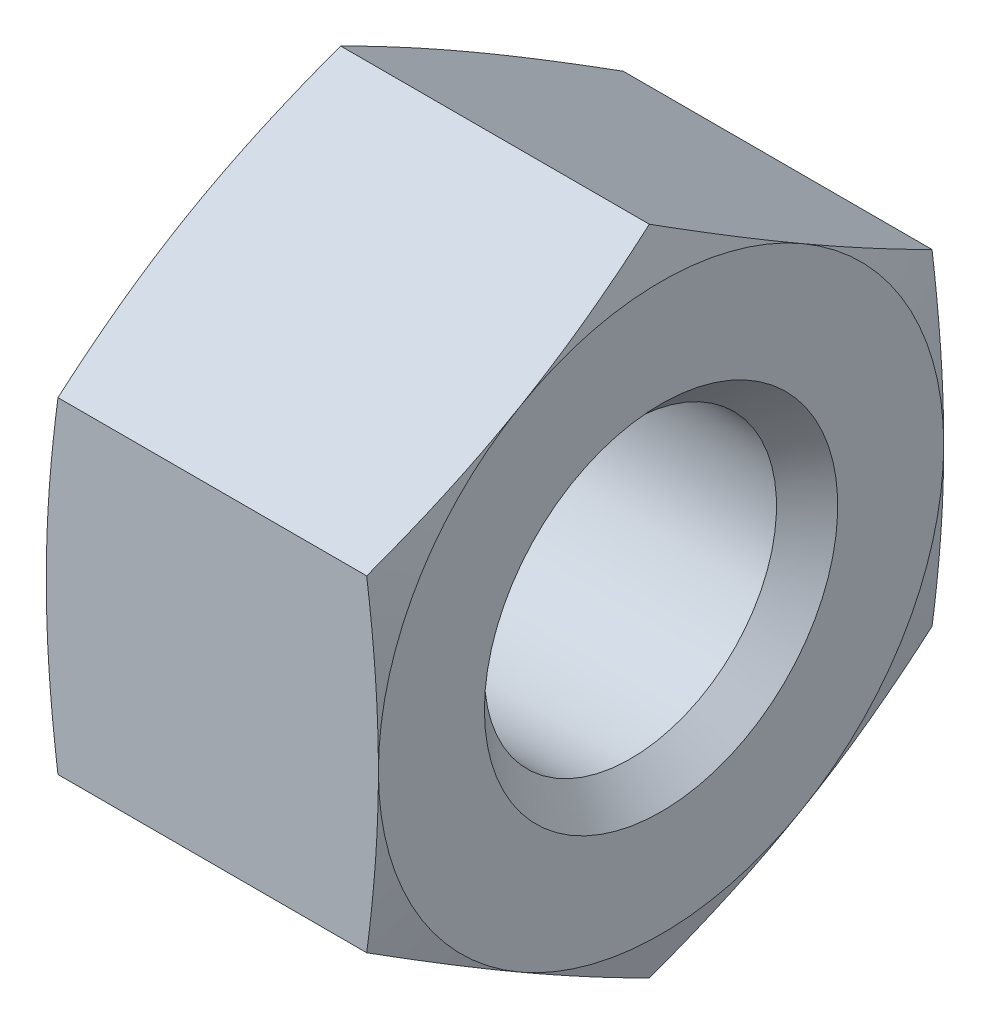
from build123d import *

# Parameters (mm, degrees)
SKETCH3_W               = 16
SKETCH3_H               = 16
CUT_EXTRUDE1_DEPTH      = 4.7
CUT_EXTRUDE1_DEPTH_BACK = 4.7


with BuildPart() as part:
    # Sketch1 → Revolve1 (revolve)
    with BuildSketch(Plane.XY):
        Polygon((-2.35, 0), (-2.35, 4), (-2.135640646, 4.8), (2.135640646, 4.8), (2.35, 4), (2.35, 0), align=None)
    revolve(axis=Axis((2.35, 0, 0), (-1, 0, 0)))

    # Sketch2 → Cut-Revolve1 (revolve, cut)
    with BuildSketch(Plane.XY):
        Polygon((-2.35, 0), (-2.35, 2.5), (-1.917, 2.067), (1.917, 2.067), (2.35, 2.5), (2.35, 0), align=None)
    revolve(axis=Axis((2.35, 0, 0), (-1, 0, 0)), mode=Mode.SUBTRACT)

    # Sketch3 → Cut-Extrude1 (cut, two sides)
    with BuildSketch(Plane(origin=(0, 0, 0), x_dir=(0, 0, -1), z_dir=(1, 0, 0))) as cut_extrude1_sk:
        Rectangle(SKETCH3_W, SKETCH3_H)
        Polygon((-4, 2.309401077), (-4, -2.309401077), (0, -4.618802154), (4, -2.309401077), (4, 2.309401077), (0, 4.618802154), align=None, mode=Mode.SUBTRACT)
    extrude(amount=CUT_EXTRUDE1_DEPTH, mode=Mode.SUBTRACT)
    extrude(cut_extrude1_sk.sketch, amount=-CUT_EXTRUDE1_DEPTH_BACK, mode=Mode.SUBTRACT)


solid = part.part
